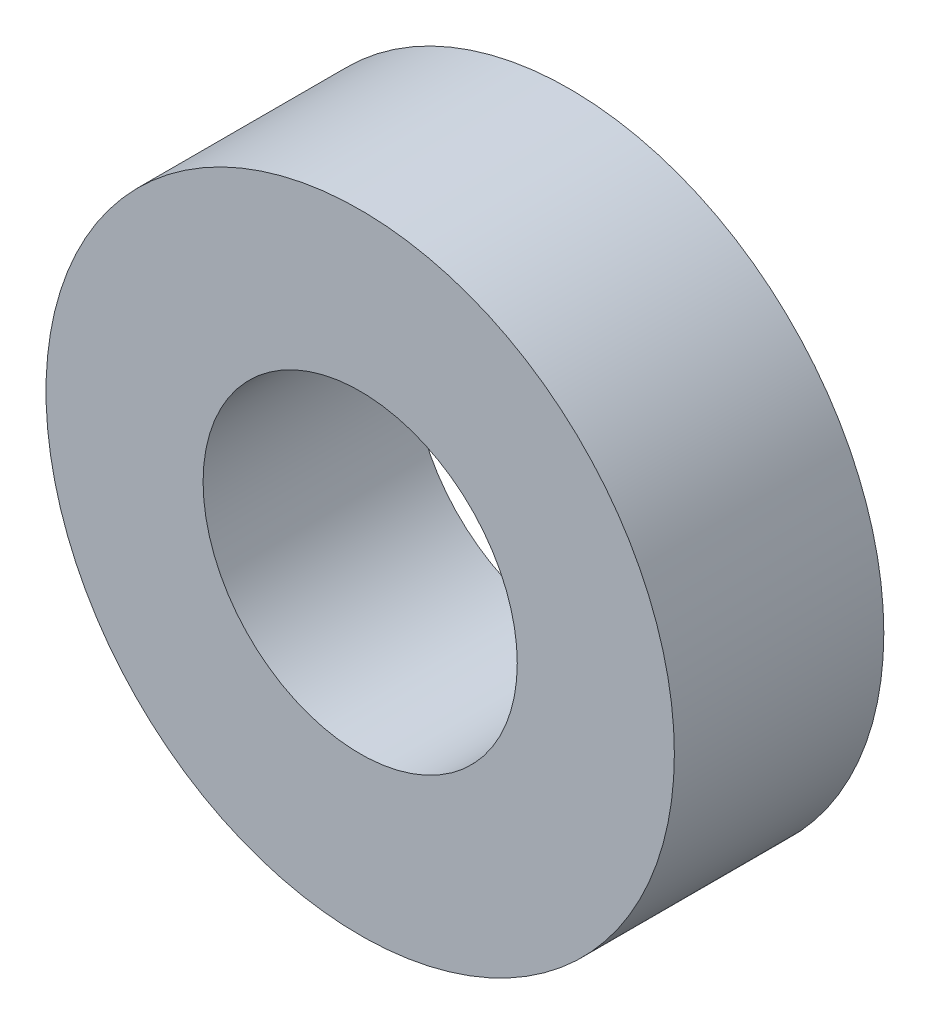
from build123d import *

# Parameters (mm, degrees)
ESQUISSE1_R      = 6
ESQUISSE1_R_2    = 3
EXTRUSION1_DEPTH = 4


with BuildPart() as part:
    # Esquisse1 → Extrusion1 (new body)
    with BuildSketch(Plane.XY):
        Circle(ESQUISSE1_R)
        Circle(ESQUISSE1_R_2, mode=Mode.SUBTRACT)
    extrude(amount=EXTRUSION1_DEPTH)


solid = part.part
